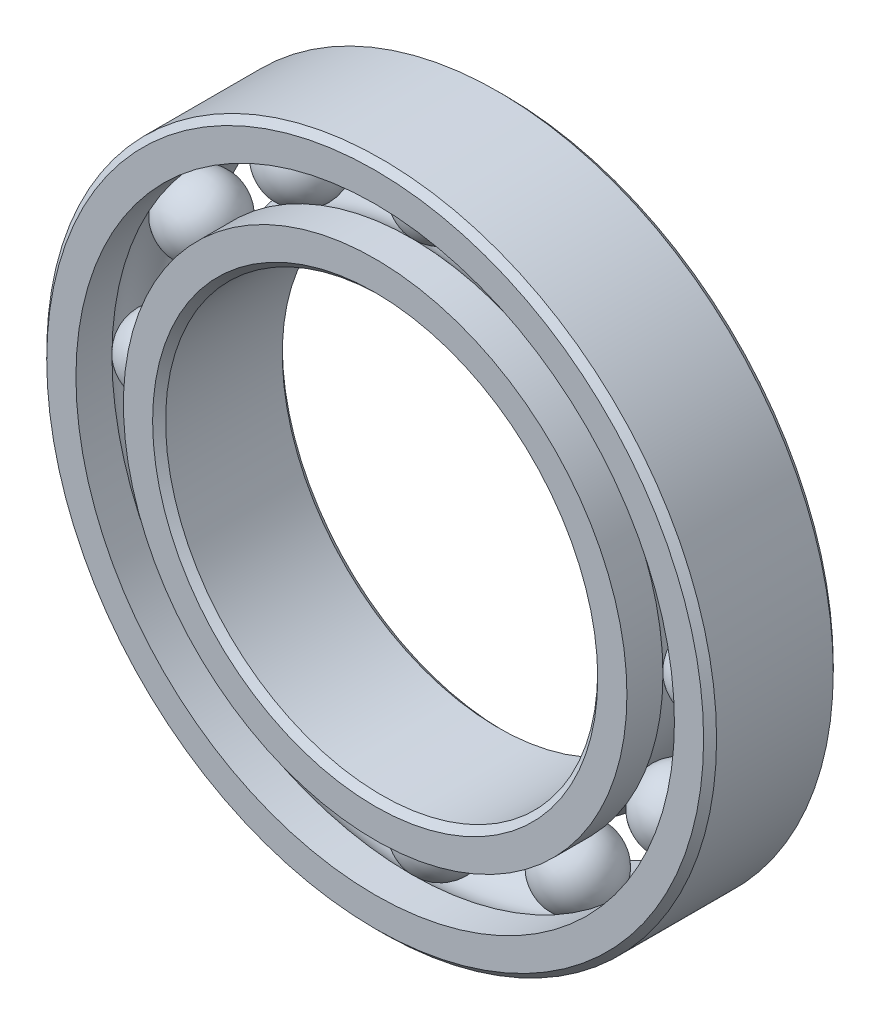
from build123d import *

# Parameters (mm, degrees)
CIRPATTERN1_COUNT = 12


with BuildPart() as part:
    # Sketch1 → Revolve1 (revolve)
    with BuildSketch(Plane(origin=(0, 0, 0), x_dir=(0, 0, -1), z_dir=(1, 0, 0))):
        with BuildLine():
            Line((5.4, 31), (-5.4, 31))
            Line((-5.4, 31), (-6, 30.4))
            Line((-6, 30.4), (-6, 27.697552198))
            Line((-6, 27.697552198), (-2.666666667, 27.697552198))
            ThreePointArc((-2.666666667, 27.697552198), (0, 28.955389682), (2.666666667, 27.697552198))
            Line((2.666666667, 27.697552198), (6, 27.697552198))
            Line((6, 27.697552198), (6, 30.4))
            Line((6, 30.4), (5.4, 31))
        make_face()
    revolve(axis=Axis((0, 0, 6), (0, 0, -1)))


with BuildPart() as body_2:
    # Sketch3 → Revolve3 (revolve)
    with BuildSketch(Plane(origin=(0, 0, 0), x_dir=(0, 0, -1), z_dir=(1, 0, 0))):
        with BuildLine():
            Line((-6, 23.301947802), (-2.666666667, 23.301947802))
            ThreePointArc((-2.666666667, 23.301947802), (0, 22.044110318), (2.666666667, 23.301947802))
            Line((2.666666667, 23.301947802), (6, 23.301947802))
            Line((6, 23.301947802), (6, 20.5995))
            Line((6, 20.5995), (5.4, 19.9995))
            Line((5.4, 19.9995), (-5.4, 19.9995))
            Line((-5.4, 19.9995), (-6, 20.5995))
            Line((-6, 20.5995), (-6, 23.301947802))
        make_face()
    revolve(axis=Axis((0, 0, 6), (0, 0, -1)))


with BuildPart() as body_3:
    # Sketch4 → Revolve4 (revolve)
    with BuildSketch(Plane(origin=(0, 0, 0), x_dir=(0, 0, -1), z_dir=(1, 0, 0))):
        with BuildLine():
            Line((-3.455639682, 25.49975), (3.455639682, 25.49975))
            ThreePointArc((3.455639682, 25.49975), (0, 28.955389682), (-3.455639682, 25.49975))
        make_face()
    revolve(axis=Axis((0, 25.49975, 3.455639682), (0, 0, -1)))


with BuildPart() as cirpattern1_1:
    # CirPattern1: pattern copy
    add(body_3.part.rotate(Axis((0, 0, -6), (0, 0, 1)), 1 * 360 / CIRPATTERN1_COUNT))


with BuildPart() as cirpattern1_2:
    # CirPattern1: pattern copy
    add(body_3.part.rotate(Axis((0, 0, -6), (0, 0, 1)), 2 * 360 / CIRPATTERN1_COUNT))


with BuildPart() as cirpattern1_3:
    # CirPattern1: pattern copy
    add(body_3.part.rotate(Axis((0, 0, -6), (0, 0, 1)), 3 * 360 / CIRPATTERN1_COUNT))


with BuildPart() as cirpattern1_4:
    # CirPattern1: pattern copy
    add(body_3.part.rotate(Axis((0, 0, -6), (0, 0, 1)), 4 * 360 / CIRPATTERN1_COUNT))


with BuildPart() as cirpattern1_5:
    # CirPattern1: pattern copy
    add(body_3.part.rotate(Axis((0, 0, -6), (0, 0, 1)), 5 * 360 / CIRPATTERN1_COUNT))


with BuildPart() as cirpattern1_6:
    # CirPattern1: pattern copy
    add(body_3.part.rotate(Axis((0, 0, -6), (0, 0, 1)), 6 * 360 / CIRPATTERN1_COUNT))


with BuildPart() as cirpattern1_7:
    # CirPattern1: pattern copy
    add(body_3.part.rotate(Axis((0, 0, -6), (0, 0, 1)), 7 * 360 / CIRPATTERN1_COUNT))


with BuildPart() as cirpattern1_8:
    # CirPattern1: pattern copy
    add(body_3.part.rotate(Axis((0, 0, -6), (0, 0, 1)), 8 * 360 / CIRPATTERN1_COUNT))


with BuildPart() as cirpattern1_9:
    # CirPattern1: pattern copy
    add(body_3.part.rotate(Axis((0, 0, -6), (0, 0, 1)), 9 * 360 / CIRPATTERN1_COUNT))


with BuildPart() as cirpattern1_10:
    # CirPattern1: pattern copy
    add(body_3.part.rotate(Axis((0, 0, -6), (0, 0, 1)), 10 * 360 / CIRPATTERN1_COUNT))


with BuildPart() as cirpattern1_11:
    # CirPattern1: pattern copy
    add(body_3.part.rotate(Axis((0, 0, -6), (0, 0, 1)), 11 * 360 / CIRPATTERN1_COUNT))


solid = Compound([part.part, body_2.part, body_3.part, cirpattern1_1.part, cirpattern1_2.part, cirpattern1_3.part, cirpattern1_4.part, cirpattern1_5.part, cirpattern1_6.part, cirpattern1_7.part, cirpattern1_8.part, cirpattern1_9.part, cirpattern1_10.part, cirpattern1_11.part])
